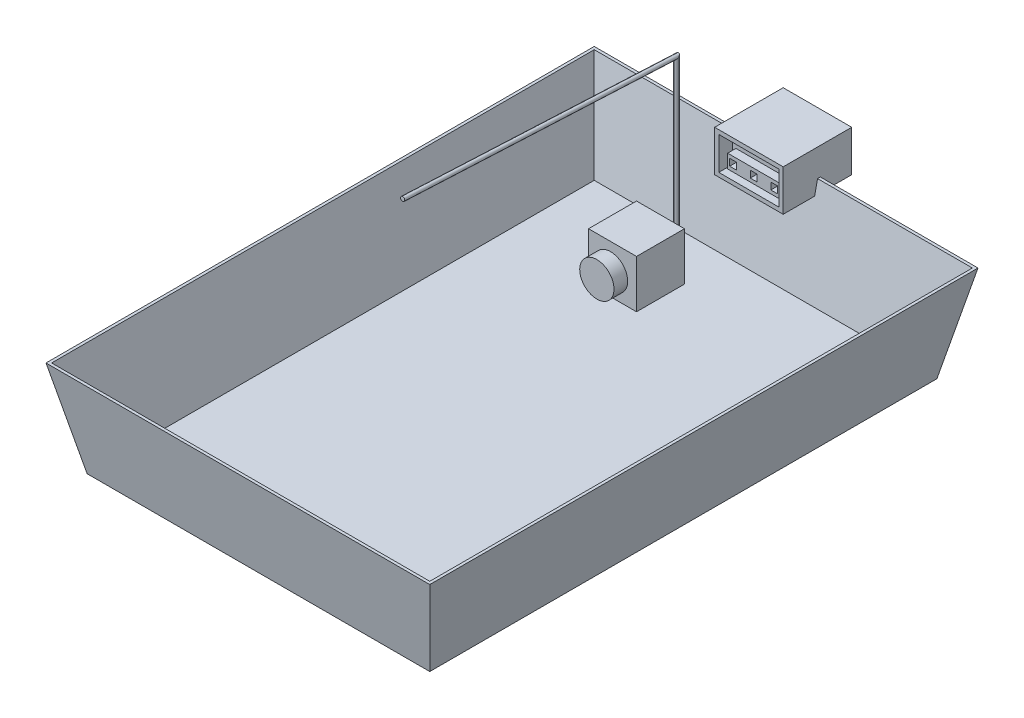
from build123d import *

# Parameters (mm, degrees)
SKETCH2_W           = 250
SKETCH2_H           = 370
SKETCH1_W           = 280
SKETCH1_H           = 400
SHELL1_T            = -2
SKETCH3_W           = 50
SKETCH3_H           = 50
CUT_EXTRUDE1_DEPTH  = 10
SKETCH4_W           = 50
SKETCH4_H           = 50
BOSS_EXTRUDE2_DEPTH = 30
SKETCH6_W           = 44
SKETCH6_H           = 24
CUT_EXTRUDE2_DEPTH  = 10
SKETCH7_W           = 40
SKETCH7_H           = 20
CUT_EXTRUDE3_DEPTH  = 10
SKETCH8_R           = 2.5
CUT_EXTRUDE4_DEPTH  = 60
SKETCH9_W           = 40
SKETCH9_H           = 10
SKETCH9_W_2         = 5
SKETCH9_H_2         = 5
BOSS_EXTRUDE3_DEPTH = 6
SKETCH10_W          = 35
SKETCH10_H          = 35
BOSS_EXTRUDE5_DEPTH = 35
SKETCH11_R          = 12.5
BOSS_EXTRUDE6_DEPTH = 10
SWEEP1_PROFILE_R    = 1.5


with BuildPart() as part:
    # Sketch2 → Loft1 section 0
    with BuildSketch(Plane(origin=(0, -70, 0), x_dir=(1, 0, 0), z_dir=(0, 1, 0))):
        Rectangle(SKETCH2_W, SKETCH2_H)
    # Sketch1 → Loft1 section 1
    with BuildSketch(Plane(origin=(0, 0, 0), x_dir=(1, 0, 0), z_dir=(0, 1, 0))):
        Rectangle(SKETCH1_W, SKETCH1_H)
    loft()

    # Shell1
    shell1_openings = [part.faces().sort_by_distance(p)[0] for p in [
        (0, 0, 0),
    ]]
    offset(amount=SHELL1_T, openings=shell1_openings, kind=Kind.INTERSECTION)

    # Sketch3 → Cut-Extrude1 (cut)
    with BuildSketch(Plane(origin=(0, 0, 0), x_dir=(1, 0, 0), z_dir=(0, 1, 0))):
        with Locations((0, 200)):
            Rectangle(SKETCH3_W, SKETCH3_H)
    extrude(amount=-CUT_EXTRUDE1_DEPTH, mode=Mode.SUBTRACT)



with BuildPart() as body_2:
    # Sketch4 → Boss-Extrude2 (new body)
    with BuildSketch(Plane(origin=(0, -10, 0), x_dir=(1, 0, 0), z_dir=(0, 1, 0))):
        with Locations((0, 197.857142857)):
            Rectangle(SKETCH4_W, SKETCH4_H)
    extrude(amount=BOSS_EXTRUDE2_DEPTH)

    # Sketch6 → Cut-Extrude2 (cut)
    with BuildSketch(Plane.XY.offset(-172.857142857)):
        with Locations((0, 5)):
            Rectangle(SKETCH6_W, SKETCH6_H)
    extrude(amount=-CUT_EXTRUDE2_DEPTH, mode=Mode.SUBTRACT)

    # Sketch7 → Cut-Extrude3 (cut)
    with BuildSketch(Plane(origin=(0, 0, -222.857142857), x_dir=(-1, 0, 0), z_dir=(0, 0, -1))):
        with Locations((0, 5)):
            Rectangle(SKETCH7_W, SKETCH7_H)
    extrude(amount=-CUT_EXTRUDE3_DEPTH, mode=Mode.SUBTRACT)

    # Sketch8 → Cut-Extrude4 (cut)
    with BuildSketch(Plane.XY.offset(-182.857142857)):
        with Locations((-15.301608644, 11.712017977)):
            Circle(SKETCH8_R)
        with Locations((-7.133483514, 11.712017977)):
            Circle(SKETCH8_R)
    extrude(amount=-CUT_EXTRUDE4_DEPTH, mode=Mode.SUBTRACT)


with BuildPart() as part_1:
    add(part.part)

    add(body_2.part)  # Boss-Extrude3 merges body 2
    # Sketch9 → Boss-Extrude3 (add)
    with BuildSketch(Plane.XY.offset(-182.857142857)):
        with Locations((0.504671377, -0.618402812)):
            Rectangle(SKETCH9_W, SKETCH9_H)
        with Locations((-15.511503932, -0.618402812)):
            Rectangle(SKETCH9_W_2, SKETCH9_H_2, mode=Mode.SUBTRACT)
        with Locations((-0.511503932, -0.618402812)):
            Rectangle(SKETCH9_W_2, SKETCH9_H_2, mode=Mode.SUBTRACT)
        with Locations((14.488496068, -0.618402812)):
            Rectangle(SKETCH9_W_2, SKETCH9_H_2, mode=Mode.SUBTRACT)
    extrude(amount=BOSS_EXTRUDE3_DEPTH)



with BuildPart() as body_2_2:
    # Sketch10 → Boss-Extrude5 (new body)
    with BuildSketch(Plane(origin=(0, -68, 0), x_dir=(1, 0, 0), z_dir=(0, 1, 0))):
        with Locations((-42.39654967, 133.244997545)):
            Rectangle(SKETCH10_W, SKETCH10_H)
    extrude(amount=BOSS_EXTRUDE5_DEPTH)


with BuildPart() as part_2:
    add(part_1.part)

    add(body_2_2.part)  # Boss-Extrude6 merges body 2 2
    # Sketch11 → Boss-Extrude6 (add)
    with BuildSketch(Plane.XY.offset(-115.744997545)):
        with Locations(Location((-43.843818636, -51.947268965, 0), (0, 0, 180))):  # turned: the seam where the file's is
            Circle(SKETCH11_R)
    extrude(amount=BOSS_EXTRUDE6_DEPTH)

    # Sweep1: sweep along a path in Sketch12
    with BuildLine(Plane.ZY.offset(34.89654967)) as sweep1_path:
        Line((-149.877541463, -51.005012101), (-154.877541463, -51.005012101))
        Line((-154.877541463, -51.005012101), (-154.877541463, 68.994987899))
        Line((-154.877541463, 68.994987899), (44.889790726, 78.639312125))
    # Sweep1 profile (on start of the path) → Sweep1 (sweep)
    with BuildSketch(Plane(origin=(-34.89654967, -51.005012101, -149.877541463), x_dir=(0, -1, 0), z_dir=(0, 0, -1))):
        Circle(SWEEP1_PROFILE_R)
    sweep(path=sweep1_path.line, transition=Transition.RIGHT)


solid = part_2.part
